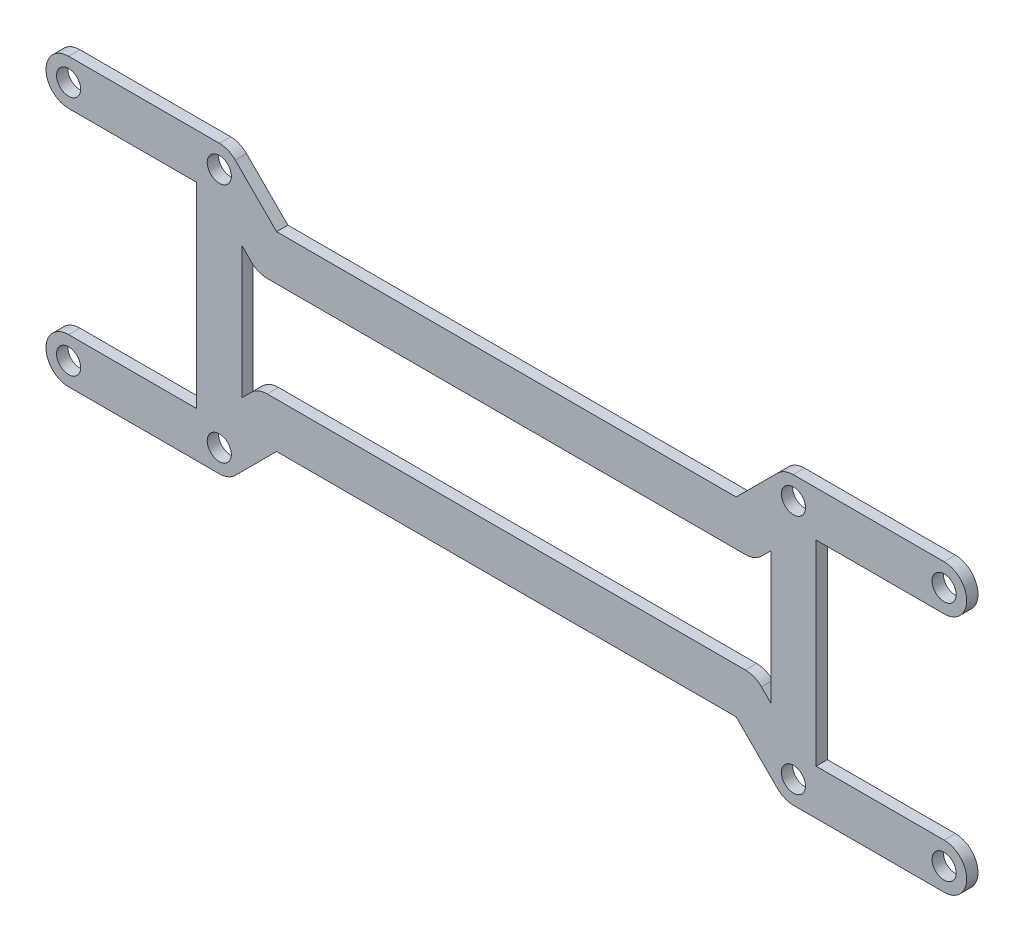
from build123d import *

# Parameters (mm, degrees)
SKETCH1_R           = 1.6
SKETCH1_W           = 70.2081528
SKETCH1_H           = 26
BOSS_EXTRUDE1_DEPTH = 1.5
SKETCH2_R           = 1.6
BOSS_EXTRUDE2_DEPTH = 1.5
CUT_EXTRUDE1_DEPTH  = 1.5


with BuildPart() as part:
    # Sketch1 → Boss-Extrude1 (new body)
    with BuildSketch(Plane.XY):
        with BuildLine():
            Line((0, -3), (20, -3))
            ThreePointArc((20, -3), (23, 0), (20, 3))
            Line((20, 3), (3, 3))
            Line((3, 3), (3, 13))
            Line((3, 13), (3, 29))
            Line((3, 29), (20, 29))
            ThreePointArc((20, 29), (23, 32), (20, 35))
            Line((20, 35), (0, 35))
            Line((0, 35), (-76.2081528, 35))
            Line((-76.2081528, 35), (-96.2081528, 35))
            ThreePointArc((-96.2081528, 35), (-99.2081528, 32), (-96.2081528, 29))
            Line((-96.2081528, 29), (-79.2081528, 29))
            Line((-79.2081528, 29), (-79.2081528, 14.5))
            Line((-79.2081528, 14.5), (-79.2081528, 3))
            Line((-79.2081528, 3), (-96.2081528, 3))
            ThreePointArc((-96.2081528, 3), (-99.2081528, 0), (-96.2081528, -3))
            Line((-96.2081528, -3), (-76.2081528, -3))
            Line((-76.2081528, -3), (0, -3))
        make_face()
        with Locations((-76.2081528, 0)):
            Circle(SKETCH1_R, mode=Mode.SUBTRACT)
        with Locations((-76.2081528, 32)):
            Circle(SKETCH1_R, mode=Mode.SUBTRACT)
        Circle(SKETCH1_R, mode=Mode.SUBTRACT)
        with Locations((20, 0)):
            Circle(SKETCH1_R, mode=Mode.SUBTRACT)
        with Locations((0, 32)):
            Circle(SKETCH1_R, mode=Mode.SUBTRACT)
        with Locations((20, 32)):
            Circle(SKETCH1_R, mode=Mode.SUBTRACT)
        with Locations((-96.2081528, 32)):
            Circle(SKETCH1_R, mode=Mode.SUBTRACT)
        with Locations((-96.2081528, 0)):
            Circle(SKETCH1_R, mode=Mode.SUBTRACT)
        with Locations((-38.1040764, 16)):
            Rectangle(SKETCH1_W, SKETCH1_H, mode=Mode.SUBTRACT)
    extrude(amount=BOSS_EXTRUDE1_DEPTH)

    # Sketch2 → Boss-Extrude2 (add)
    with BuildSketch(Plane.XY.offset(1.5)):
        with BuildLine():
            Line((-74.086832456, 34.121320344), (-68.601551082, 28.636038969))
            Line((-68.601551082, 28.636038969), (-7.606601718, 28.636038969))
            Line((-7.606601718, 28.636038969), (-2.121320344, 34.121320344))
            ThreePointArc((-2.121320344, 34.121320344), (2.121320344, 34.121320344), (2.121320344, 29.878679656))
            Line((2.121320344, 29.878679656), (-4.242640687, 23.514718626))
            ThreePointArc((-4.242640687, 23.514718626), (-5.215910734, 22.864400372), (-6.363961031, 22.636038969))
            Line((-6.363961031, 22.636038969), (-69.844191769, 22.636038969))
            ThreePointArc((-69.844191769, 22.636038969), (-70.992242066, 22.864400372), (-71.965512113, 23.514718626))
            Line((-71.965512113, 23.514718626), (-78.329473144, 29.878679656))
            ThreePointArc((-78.329473144, 29.878679656), (-78.329473144, 34.121320344), (-74.086832456, 34.121320344))
        make_face()
        with Locations((0, 32)):
            Circle(SKETCH2_R, mode=Mode.SUBTRACT)
        with Locations((-76.2081528, 32)):
            Circle(SKETCH2_R, mode=Mode.SUBTRACT)
        with BuildLine():
            Line((-69.844191769, 9.363961031), (-6.363961031, 9.363961031))
            ThreePointArc((-6.363961031, 9.363961031), (-5.215910734, 9.135599628), (-4.242640687, 8.485281374))
            Line((-4.242640687, 8.485281374), (2.121320344, 2.121320344))
            ThreePointArc((2.121320344, 2.121320344), (2.121320344, -2.121320344), (-2.121320344, -2.121320344))
            Line((-2.121320344, -2.121320344), (-7.606601718, 3.363961031))
            Line((-7.606601718, 3.363961031), (-68.601551082, 3.363961031))
            Line((-68.601551082, 3.363961031), (-74.086832456, -2.121320344))
            ThreePointArc((-74.086832456, -2.121320344), (-78.329473144, -2.121320344), (-78.329473144, 2.121320344))
            Line((-78.329473144, 2.121320344), (-71.965512113, 8.485281374))
            ThreePointArc((-71.965512113, 8.485281374), (-70.992242066, 9.135599628), (-69.844191769, 9.363961031))
        make_face()
        with Locations((-76.2081528, 0)):
            Circle(SKETCH2_R, mode=Mode.SUBTRACT)
        Circle(SKETCH2_R, mode=Mode.SUBTRACT)
    extrude(amount=-BOSS_EXTRUDE2_DEPTH)

    # Sketch3 → Cut-Extrude1 (cut)
    with BuildSketch(Plane.XY.offset(1.5)):
        with BuildLine():
            Line((-68.601551082, 28.636038969), (-74.088420945, 34.12061745))
            ThreePointArc((-74.088420945, 34.12061745), (-75.061011799, 34.770261546), (-76.2081528, 34.998379814))
            Line((-76.2081528, 34.998379814), (-76.2081528, 40.296736943))
            Line((-76.2081528, 40.296736943), (0, 40.296736943))
            Line((0, 40.296736943), (0, 35.000078273))
            ThreePointArc((0, 35.000078273), (-1.148094234, 34.77170512), (-2.121397096, 34.121354286))
            Line((-2.121397096, 34.121354286), (-7.606601718, 28.636038969))
            Line((-7.606601718, 28.636038969), (-68.601551082, 28.636038969))
        make_face()
        with BuildLine():
            Line((-76.2081528, -8.296736943), (-76.2081528, -2.998379814))
            ThreePointArc((-76.2081528, -2.998379814), (-75.061011799, -2.770261546), (-74.088420945, -2.12061745))
            Line((-74.088420945, -2.12061745), (-68.601551082, 3.363961031))
            Line((-68.601551082, 3.363961031), (-7.606601718, 3.363961031))
            Line((-7.606601718, 3.363961031), (-2.121397096, -2.121354286))
            ThreePointArc((-2.121397096, -2.121354286), (-1.148094234, -2.77170512), (0, -3.000078273))
            Line((0, -3.000078273), (0, -8.296736943))
            Line((0, -8.296736943), (-76.2081528, -8.296736943))
        make_face()
    extrude(amount=-CUT_EXTRUDE1_DEPTH, mode=Mode.SUBTRACT)


solid = part.part
